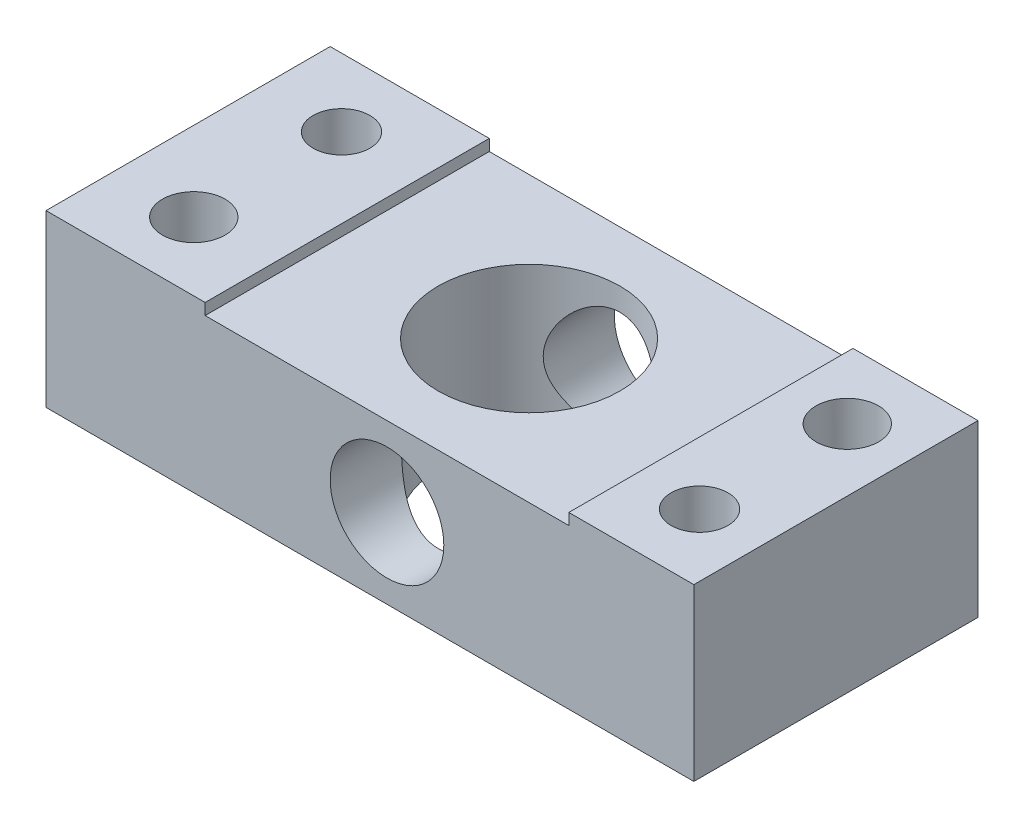
from build123d import *

# Parameters (mm, degrees)
SKETCH1_W           = 57
SKETCH1_H           = 19
BOSS_EXTRUDE1_DEPTH = 15
SKETCH2_W           = 32
SKETCH2_H           = 1
CUT_EXTRUDE1_DEPTH  = 22
SKETCH3_R           = 5
CUT_EXTRUDE2_DEPTH  = 22
BOSS_EXTRUDE2_DEPTH = 6
SKETCH6_R           = 2.75
SKETCH6_R_2         = 2.5
CUT_EXTRUDE5_DEPTH  = 58.7
SKETCH8_R           = 5
CUT_EXTRUDE6_DEPTH  = 5.7
SKETCH9_R           = 8
CUT_EXTRUDE7_DEPTH  = 15.7
SKETCH10_R          = 5
CUT_EXTRUDE8_DEPTH  = 56.7
SKETCH11_R          = 8
BOSS_EXTRUDE3_DEPTH = 14
SKETCH12_R          = 5
BOSS_EXTRUDE4_DEPTH = 25
SKETCH13_R          = 8
CUT_EXTRUDE9_DEPTH  = 171
SKETCH14_R          = 5
CUT_EXTRUDE10_DEPTH = 171


with BuildPart() as part:
    # Sketch1 → Boss-Extrude1 (new body)
    with BuildSketch(Plane(origin=(0, 0, 0), x_dir=(1, 0, 0), z_dir=(0, 1, 0))):
        Rectangle(SKETCH1_W, SKETCH1_H)
    extrude(amount=BOSS_EXTRUDE1_DEPTH)

    # Sketch2 → Cut-Extrude1 (cut)
    with BuildSketch(Plane.XY.offset(9.5)):
        with Locations((1.5, 14.5)):
            Rectangle(SKETCH2_W, SKETCH2_H)
    extrude(amount=-CUT_EXTRUDE1_DEPTH, mode=Mode.SUBTRACT)

    # Sketch3 → Cut-Extrude2 (cut)
    with BuildSketch(Plane.XY.offset(9.5)):
        with Locations((0, 7)):
            Circle(SKETCH3_R)
    extrude(amount=-CUT_EXTRUDE2_DEPTH, mode=Mode.SUBTRACT)

    # Sketch5 → Boss-Extrude2 (add)
    with BuildSketch(Plane.XY.offset(9.5)):
        Polygon((-28.5, 15), (-14.5, 15), (-14.5, 14), (17.5, 14), (17.5, 15), (28.5, 15), (28.5, 0), (-28.5, 0), align=None)
    extrude(amount=BOSS_EXTRUDE2_DEPTH)

    # Sketch6 → Cut-Extrude5 (cut)
    with BuildSketch(Plane.XZ):
        with Locations((-21.5, 9.5)):
            Circle(SKETCH6_R)
        with Locations((23, -3.5)):
            Circle(SKETCH6_R)
        with Locations((-21.5, -3.5)):
            Circle(SKETCH6_R_2)
        with Locations((23, 9.5)):
            Circle(SKETCH6_R_2)
    extrude(amount=-CUT_EXTRUDE5_DEPTH, mode=Mode.SUBTRACT)

    # Sketch8 → Cut-Extrude6 (cut)
    with BuildSketch(Plane.XZ):
        with Locations((-21.5, 9.5)):
            Circle(SKETCH8_R)
        with Locations((23, -3.5)):
            Circle(SKETCH8_R)
    extrude(amount=-CUT_EXTRUDE6_DEPTH, mode=Mode.SUBTRACT)

    # Sketch9 → Cut-Extrude7 (cut)
    with BuildSketch(Plane.XZ):
        with Locations((0, 3)):
            Circle(SKETCH9_R)
    extrude(amount=-CUT_EXTRUDE7_DEPTH, mode=Mode.SUBTRACT)

    # Sketch10 → Cut-Extrude8 (cut)
    with BuildSketch(Plane(origin=(0, 0, -9.5), x_dir=(-1, 0, 0), z_dir=(0, 0, -1))):
        with Locations((0, 7)):
            Circle(SKETCH10_R)
    extrude(amount=-CUT_EXTRUDE8_DEPTH, mode=Mode.SUBTRACT)

    # Sketch11 → Boss-Extrude3 (add)
    with BuildSketch(Plane.XZ):
        with Locations((0, 3)):
            Circle(SKETCH11_R)
    extrude(amount=-BOSS_EXTRUDE3_DEPTH)

    # Sketch12 → Boss-Extrude4 (add)
    with BuildSketch(Plane.XY.offset(15.5)):
        with Locations((0, 7)):
            Circle(SKETCH12_R)
    extrude(amount=-BOSS_EXTRUDE4_DEPTH)

    # Sketch13 → Cut-Extrude9 (cut)
    with BuildSketch(Plane.XZ):
        with Locations((1.5, 3)):
            Circle(SKETCH13_R)
    extrude(amount=-CUT_EXTRUDE9_DEPTH, mode=Mode.SUBTRACT)

    # Sketch14 → Cut-Extrude10 (cut)
    with BuildSketch(Plane.XY.offset(15.5)):
        with Locations((1.5, 7)):
            Circle(SKETCH14_R)
    extrude(amount=-CUT_EXTRUDE10_DEPTH, mode=Mode.SUBTRACT)


solid = part.part
